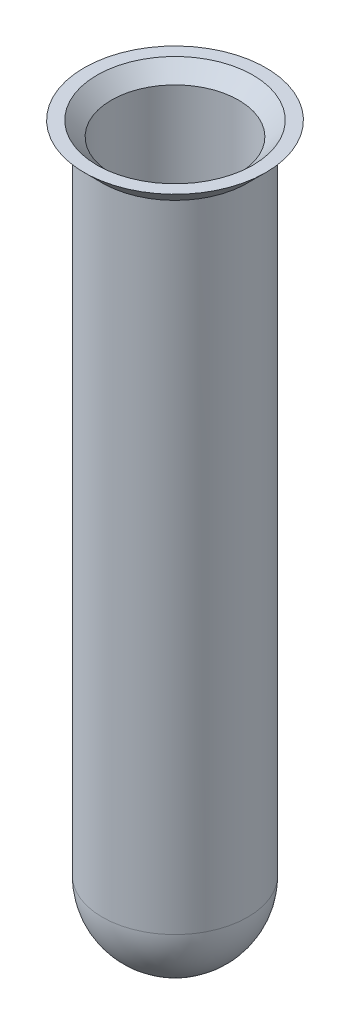
from build123d import *

# Parameters (mm, degrees)
SHELL8_T = -1


with BuildPart() as part:
    # Sketch1 → Revolve2 (revolve)
    with BuildSketch(Plane.XY):
        with BuildLine():
            Line((0, 3.677706493), (10, 3.677706493))
            Line((10, 3.677706493), (8, 1.677706493))
            Line((8, 1.677706493), (8, -68.322293507))
            ThreePointArc((8, -68.322293507), (5.656854249, -73.979147757), (0, -76.322293507))
            Line((0, -76.322293507), (0, 3.677706493))
        make_face()
    revolve(axis=Axis((0, 3.677706493, 0), (0, -1, 0)))

    # Shell8
    shell8_openings = [part.faces().sort_by_distance(p)[0] for p in [
        (-10, 3.677706493, 0),
    ]]
    offset(amount=SHELL8_T, openings=shell8_openings, kind=Kind.INTERSECTION)


solid = part.part
